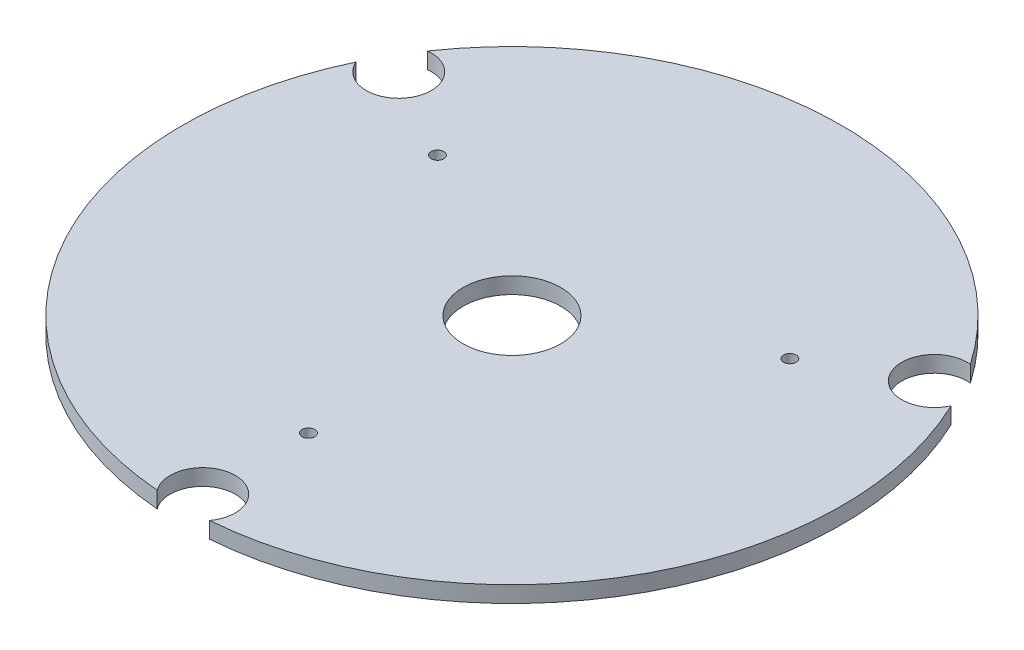
from build123d import *

# Parameters (mm, degrees)
SKETCH1_R           = 81
SKETCH1_R_2         = 1.55
SKETCH1_R_3         = 12
BOSS_EXTRUDE1_DEPTH = 2
CUT_EXTRUDE1_DEPTH  = 5


with BuildPart() as part:
    # Sketch1 → Boss-Extrude1 (new body, symmetric)
    with BuildSketch(Plane(origin=(0, 0, 0), x_dir=(1, 0, 0), z_dir=(0, 1, 0))):
        Circle(SKETCH1_R)
        with Locations((43.301270189, 25)):
            Circle(SKETCH1_R_2, mode=Mode.SUBTRACT)
        with Locations((0, -50)):
            Circle(SKETCH1_R_2, mode=Mode.SUBTRACT)
        with Locations((-43.301270189, 25)):
            Circle(SKETCH1_R_2, mode=Mode.SUBTRACT)
        Circle(SKETCH1_R_3, mode=Mode.SUBTRACT)
    extrude(amount=BOSS_EXTRUDE1_DEPTH, both=True)

    # Sketch2 → Cut-Extrude1 (cut, through all)
    with BuildSketch(Plane.XZ.offset(2)):
        with BuildLine():
            ThreePointArc((-66.704830818, -45.950686018), (-58.889727457, -34), (-73.146876822, -34.792735035))
            ThreePointArc((-73.146876822, -34.792735035), (-70.148057707, -40.5), (-66.704830818, -45.950686018))
        make_face()
        with BuildLine():
            ThreePointArc((66.704830818, -45.950686018), (70.148057707, -40.5), (73.146876822, -34.792735035))
            ThreePointArc((73.146876822, -34.792735035), (58.889727457, -34), (66.704830818, -45.950686018))
        make_face()
        with BuildLine():
            ThreePointArc((-6.442046004, 80.743421053), (0, 68), (6.442046004, 80.743421053))
            ThreePointArc((6.442046004, 80.743421053), (0, 81), (-6.442046004, 80.743421053))
        make_face()
    extrude(amount=-CUT_EXTRUDE1_DEPTH, mode=Mode.SUBTRACT)


solid = part.part
